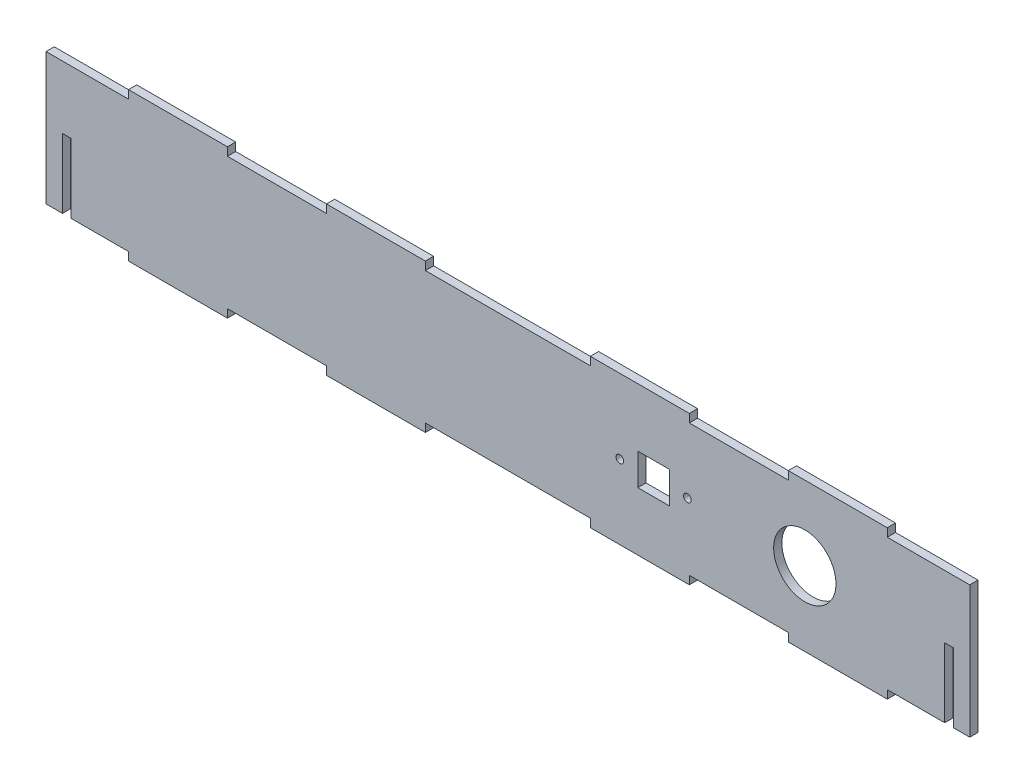
from build123d import *

# Parameters (mm, degrees)
SKETCH1_W               = 355.6
SKETCH1_H               = 50.8
BOSS_EXTRUDE1_DEPTH     = 3.175
SKETCH2_W               = 38.1
SKETCH2_H               = 3.175
BOSS_EXTRUDE2_DEPTH     = 3.175
MIRROR2_COPY_1_SKETCH_W = 38.1
MIRROR2_COPY_1_SKETCH_H = 3.175
MIRROR2_COPY_1_DEPTH    = 3.175
SKETCH3_W               = 3.302
SKETCH3_H               = 26.67
CUT_EXTRUDE1_DEPTH      = 3.175
SKETCH4_R               = 1.4732
SKETCH4_R_2             = 12
SKETCH4_W               = 12.192
SKETCH4_H               = 12.192
CUT_EXTRUDE2_DEPTH      = 1
CUT_EXTRUDE2_DEPTH_BACK = 4.175


with BuildPart() as part:
    # Sketch1 → Boss-Extrude1 (new body)
    with BuildSketch(Plane.XY):
        with Locations((177.8, 25.4)):
            Rectangle(SKETCH1_W, SKETCH1_H)
    extrude(amount=BOSS_EXTRUDE1_DEPTH)

    # Sketch2 → Boss-Extrude2 (add)
    with BuildSketch(Plane(origin=(0, 50.8, 0), x_dir=(1, 0, 0), z_dir=(0, 1, 0))):
        with Locations((50.8, -1.5875)):
            Rectangle(SKETCH2_W, SKETCH2_H)
        with Locations((127, -1.5875)):
            Rectangle(SKETCH2_W, SKETCH2_H)
    boss_extrude2 = extrude(amount=BOSS_EXTRUDE2_DEPTH)

    # Mirror1: Boss-Extrude2 across plane
    add(boss_extrude2.mirror(Plane.ZY.offset(-177.8)))

    # Mirror2: Boss-Extrude2 across plane
    add(boss_extrude2.mirror(Plane.ZX.offset(25.4)))

    # Mirror2 copy 1 sketch → Mirror2 copy 1 (add)
    with BuildSketch(Plane(origin=(355.6, 0, 0), x_dir=(-1, 0, 0), z_dir=(0, -1, 0))):
        with Locations((50.8, -1.5875)):
            Rectangle(MIRROR2_COPY_1_SKETCH_W, MIRROR2_COPY_1_SKETCH_H)
        with Locations((127, -1.5875)):
            Rectangle(MIRROR2_COPY_1_SKETCH_W, MIRROR2_COPY_1_SKETCH_H)
    extrude(amount=MIRROR2_COPY_1_DEPTH)

    # Sketch3 → Cut-Extrude1 (cut)
    with BuildSketch(Plane(origin=(0, 0, 0), x_dir=(-1, 0, 0), z_dir=(0, 0, -1))):
        with Locations((-8.001, 13.335)):
            Rectangle(SKETCH3_W, SKETCH3_H)
    cut_extrude1 = extrude(amount=-CUT_EXTRUDE1_DEPTH, mode=Mode.SUBTRACT)

    # Mirror3: Cut-Extrude1 across plane
    add(cut_extrude1.mirror(Plane.ZY.offset(-177.8)), mode=Mode.SUBTRACT)

    # Sketch4 → Cut-Extrude2 (cut, two sides)
    with BuildSketch(Plane(origin=(0, 0, 0), x_dir=(-1, 0, 0), z_dir=(0, 0, -1))) as cut_extrude2_sk:
        with Locations((-220.9, 25.4)):
            Circle(SKETCH4_R)
        with Locations((-246.9, 25.4)):
            Circle(SKETCH4_R)
        with Locations((-292.1, 25.4)):
            Circle(SKETCH4_R_2)
        with Locations((-233.9, 25.4)):
            Rectangle(SKETCH4_W, SKETCH4_H)
    extrude(amount=CUT_EXTRUDE2_DEPTH, mode=Mode.SUBTRACT)
    extrude(cut_extrude2_sk.sketch, amount=-CUT_EXTRUDE2_DEPTH_BACK, mode=Mode.SUBTRACT)


solid = part.part
